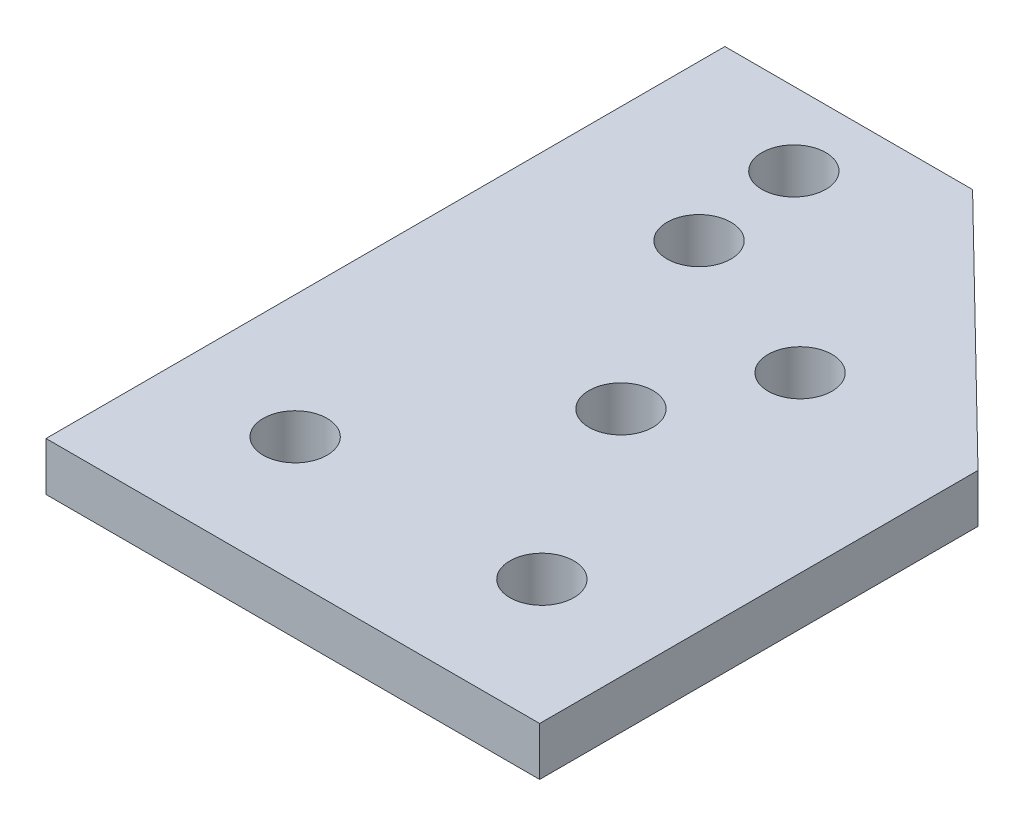
from build123d import *

# Parameters (mm, degrees)
SKETCH1_R           = 3.295
BOSS_EXTRUDE1_DEPTH = 5


with BuildPart() as part:
    # Sketch1 → Boss-Extrude1 (new body)
    with BuildSketch(Plane(origin=(0, 0, 0), x_dir=(1, 0, 0), z_dir=(0, 1, 0))):
        Polygon((0, 0), (0, 70), (25.54, 70), (50.9, 45.2), (50.9, 0), align=None)
        with Locations((14.667483235, 62.445)):
            Circle(SKETCH1_R, mode=Mode.SUBTRACT)
        with Locations((33.008944764, 44.743844982)):
            Circle(SKETCH1_R, mode=Mode.SUBTRACT)
        with Locations((12.695, 12.995)):
            Circle(SKETCH1_R, mode=Mode.SUBTRACT)
        with Locations((38.135, 12.995)):
            Circle(SKETCH1_R, mode=Mode.SUBTRACT)
        with Locations((16, 51.333944626)):
            Circle(SKETCH1_R, mode=Mode.SUBTRACT)
        with Locations((27, 32.281385742)):
            Circle(SKETCH1_R, mode=Mode.SUBTRACT)
    extrude(amount=BOSS_EXTRUDE1_DEPTH)


solid = part.part
